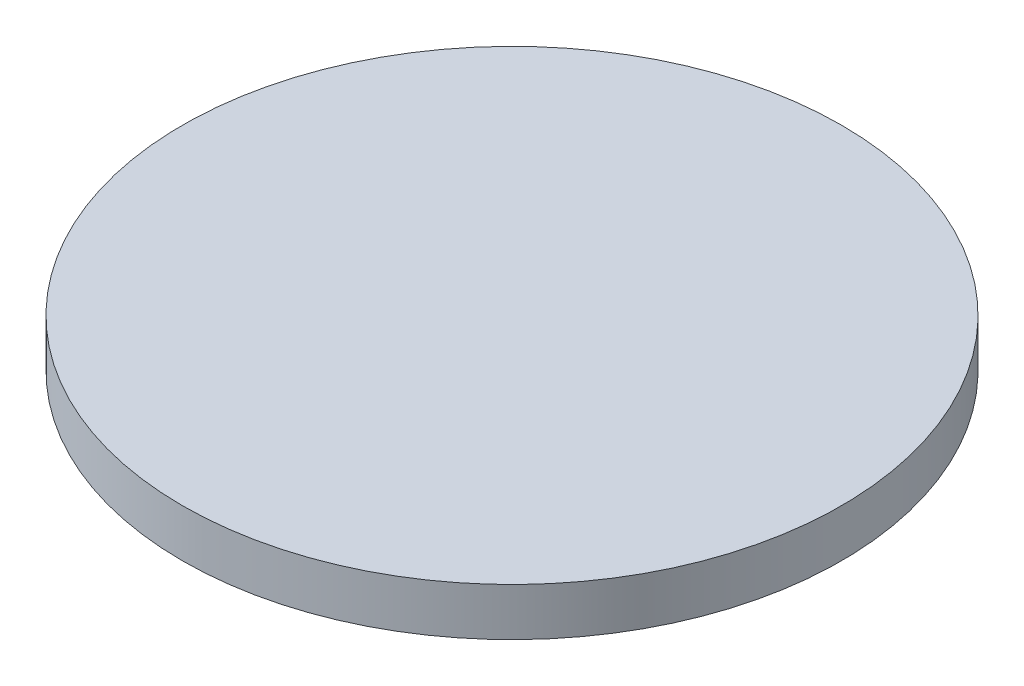
from build123d import *

# Parameters (mm, degrees)
SKETCH_1_R      = 69
EXTRUDE_1_DEPTH = 10


with BuildPart() as part:
    # Эскиз1 → Бобышка-Вытянуть1 (new body)
    with BuildSketch(Plane(origin=(0, 0, 0), x_dir=(1, 0, 0), z_dir=(0, 1, 0))):
        Circle(SKETCH_1_R)
    extrude(amount=EXTRUDE_1_DEPTH)


solid = part.part
